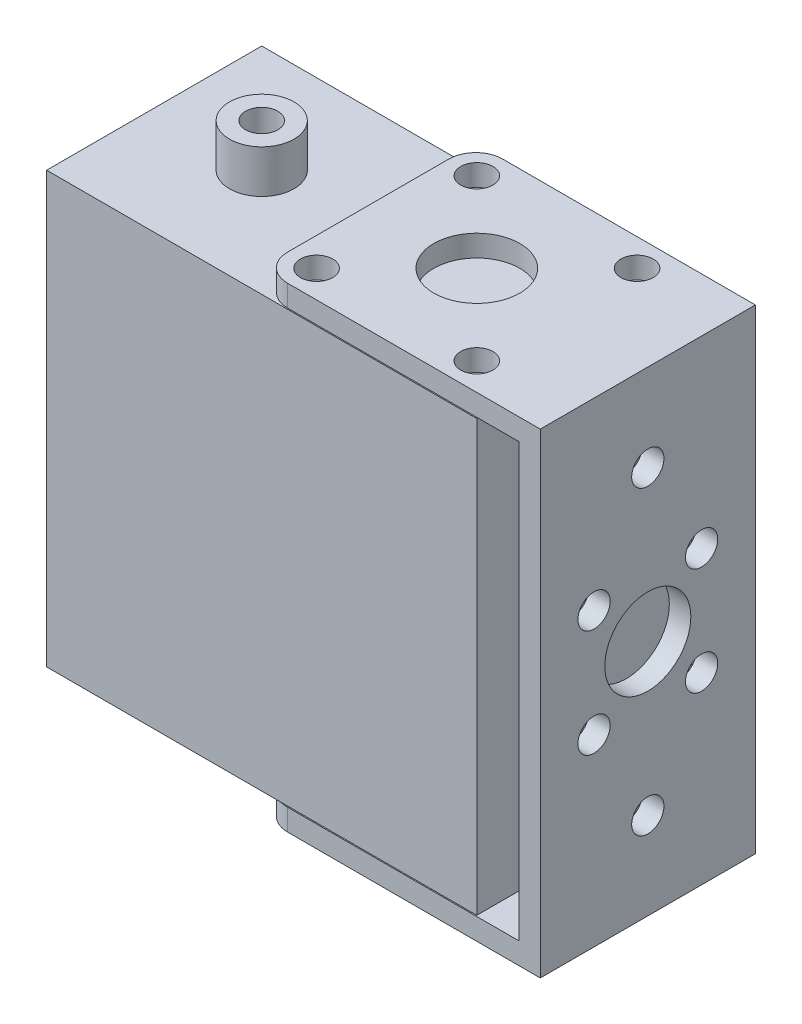
from build123d import *

# Parameters (mm, degrees)
SALIENTE_EXTRUIR1_DEPTH    = 20
CORTAR_EXTRUIR1_DEPTH      = 45.2
CROQUIS3_R                 = 4
CROQUIS3_R_2               = 1.5
CORTAR_EXTRUIR2_DEPTH      = 1
CORTAR_EXTRUIR2_DEPTH_BACK = 45.2
CROQUIS4_R                 = 4
CROQUIS4_R_2               = 1.5
CORTAR_EXTRUIR3_DEPTH      = 20
CROQUIS5_R                 = 1.5
CORTAR_EXTRUIR4_DEPTH      = 20
CROQUIS7_R                 = 1
SALIENTE_EXTRUIR2_DEPTH    = 10
CROQUIS8_W                 = 20
CROQUIS8_H                 = 20
CROQUIS8_R                 = 1.5
SALIENTE_EXTRUIR4_DEPTH    = 20
CROQUIS9_R                 = 3
CROQUIS9_R_2               = 1.5
SALIENTE_EXTRUIR5_DEPTH    = 4


with BuildPart() as part:
    # Croquis1 → Saliente-Extruir1 (new body)
    with BuildSketch(Plane.XY):
        Polygon((11, -20.1), (-13, -20.1), (-13, -22.1), (13, -22.1), (13, 22.1), (-13, 22.1), (-13, 20.1), (11, 20.1), align=None)
    extrude(amount=SALIENTE_EXTRUIR1_DEPTH)

    # Croquis2 → Cortar-Extruir1 (cut, through all)
    with BuildSketch(Plane(origin=(0, 22.1, 0), x_dir=(1, 0, 0), z_dir=(0, 1, 0))):
        with BuildLine():
            Line((-13, -17.5), (-13, -20))
            Line((-13, -20), (-10.5, -20))
            ThreePointArc((-10.5, -20), (-12.267766953, -19.267766953), (-13, -17.5))
        make_face()
        with BuildLine():
            Line((-13, 0), (-13, -2.5))
            ThreePointArc((-13, -2.5), (-12.267766953, -0.732233047), (-10.5, 0))
            Line((-10.5, 0), (-13, 0))
        make_face()
    extrude(amount=-CORTAR_EXTRUIR1_DEPTH, mode=Mode.SUBTRACT)

    # Croquis3 → Cortar-Extruir2 (cut, two sides)
    with BuildSketch(Plane(origin=(0, 22.1, 0), x_dir=(1, 0, 0), z_dir=(0, 1, 0))) as cortar_extruir2_sk:
        with Locations((-2.9, -10)):
            Circle(CROQUIS3_R)
        with Locations((-10.35, -17.45)):
            Circle(CROQUIS3_R_2)
        with Locations((-10.35, -2.55)):
            Circle(CROQUIS3_R_2)
        with Locations((4.55, -17.45)):
            Circle(CROQUIS3_R_2)
        with Locations((4.55, -2.55)):
            Circle(CROQUIS3_R_2)
    extrude(amount=CORTAR_EXTRUIR2_DEPTH, mode=Mode.SUBTRACT)
    extrude(cortar_extruir2_sk.sketch, amount=-CORTAR_EXTRUIR2_DEPTH_BACK, mode=Mode.SUBTRACT)

    # Croquis4 → Cortar-Extruir3 (cut)
    with BuildSketch(Plane(origin=(13, 0, 0), x_dir=(0, 0, -1), z_dir=(1, 0, 0))):
        with Locations((-10, 0)):
            Circle(CROQUIS4_R)
        with Locations((-15, 5)):
            Circle(CROQUIS4_R_2)
        with Locations((-5, 5)):
            Circle(CROQUIS4_R_2)
        with Locations((-5, -5)):
            Circle(CROQUIS4_R_2)
        with Locations((-15, -5)):
            Circle(CROQUIS4_R_2)
    extrude(amount=-CORTAR_EXTRUIR3_DEPTH, mode=Mode.SUBTRACT)

    # Croquis5 → Cortar-Extruir4 (cut)
    with BuildSketch(Plane(origin=(13, 0, 0), x_dir=(0, 0, -1), z_dir=(1, 0, 0))):
        with Locations((-10, 14)):
            Circle(CROQUIS5_R)
        with Locations((-10, -14)):
            Circle(CROQUIS5_R)
    extrude(amount=-CORTAR_EXTRUIR4_DEPTH, mode=Mode.SUBTRACT)


with BuildPart() as body_2:
    # Croquis7 → Saliente-Extruir2 (new body, symmetric)
    with BuildSketch(Plane(origin=(0, 0, 0), x_dir=(1, 0, 0), z_dir=(0, 1, 0))):
        with Locations((-22.9, -10)):
            Circle(CROQUIS7_R)
    extrude(amount=SALIENTE_EXTRUIR2_DEPTH, both=True)


with BuildPart() as body_3:
    # Croquis8 → Saliente-Extruir4 (new body, symmetric)
    with BuildSketch(Plane(origin=(0, 0, 0), x_dir=(1, 0, 0), z_dir=(0, 1, 0))):
        with Locations((-22.9, -10)):
            Rectangle(CROQUIS8_W, CROQUIS8_H)
        with Locations((-22.9, -10)):
            Circle(CROQUIS8_R, mode=Mode.SUBTRACT)
        with Locations((-2.9, -10)):
            Rectangle(CROQUIS8_W, CROQUIS8_H)
    extrude(amount=SALIENTE_EXTRUIR4_DEPTH, both=True)

    # Croquis9 → Saliente-Extruir5 (add)
    with BuildSketch(Plane(origin=(0, -20, 0), x_dir=(-1, 0, 0), z_dir=(0, -1, 0))):
        with Locations((22.9, -10)):
            Circle(CROQUIS9_R)
        with Locations((22.9, -10)):
            Circle(CROQUIS9_R_2, mode=Mode.SUBTRACT)
    saliente_extruir5 = extrude(amount=SALIENTE_EXTRUIR5_DEPTH)

    # Simetría1: Saliente-Extruir5 across plane
    add(saliente_extruir5.mirror(Plane.ZX))


solid = Compound([part.part, body_2.part, body_3.part])
